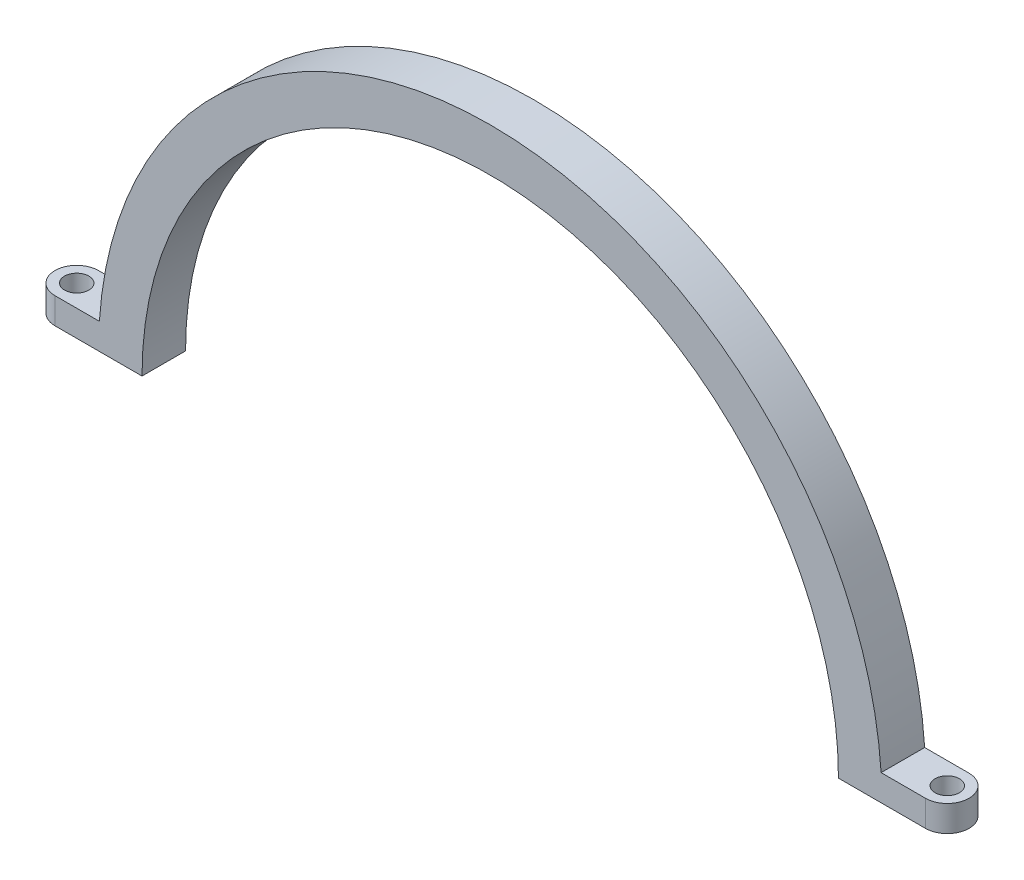
from build123d import *

# Parameters (mm, degrees)
EXTRUDE_1_DEPTH = 5
SKETCH_2_R      = 1.4
EXTRUDE_2_DEPTH = 3


with BuildPart() as part:
    # 草图1 → 凸台-拉伸1 (new body)
    with BuildSketch(Plane.XY):
        with BuildLine():
            Line((-45, 0), (-40, 0))
            ThreePointArc((-40, 0), (0, 40), (40, 0))
            Line((40, 0), (45, 0))
            ThreePointArc((45, 0), (0, 45), (-45, 0))
        make_face()
    extrude(amount=EXTRUDE_1_DEPTH)

    # 草图2 → 凸台-拉伸2 (add)
    with BuildSketch(Plane.XZ):
        with BuildLine():
            Line((-45, 5), (-50, 5))
            ThreePointArc((-50, 5), (-52.5, 2.5), (-50, 0))
            Line((-50, 0), (-45, 0))
            Line((-45, 0), (-44.132295493, 0))
            Line((-44.132295493, 0), (-44.132295493, 5))
            Line((-44.132295493, 5), (-45, 5))
        make_face()
        with Locations((-50, 2.5)):
            Circle(SKETCH_2_R, mode=Mode.SUBTRACT)
        with BuildLine():
            Line((44.132295493, 5), (44.132295493, 0))
            Line((44.132295493, 0), (45, 0))
            Line((45, 0), (50, 0))
            ThreePointArc((50, 0), (52.5, 2.5), (50, 5))
            Line((50, 5), (45, 5))
            Line((45, 5), (44.132295493, 5))
        make_face()
        with Locations((50, 2.5)):
            Circle(SKETCH_2_R, mode=Mode.SUBTRACT)
    extrude(amount=-EXTRUDE_2_DEPTH)


solid = part.part
